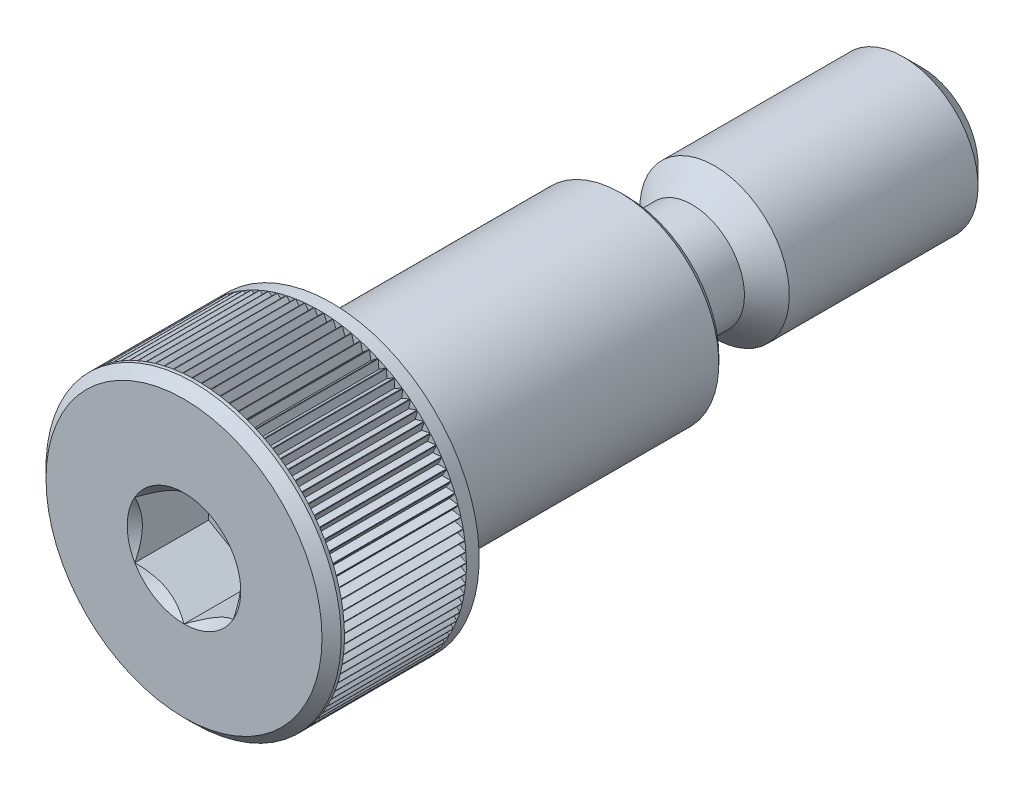
from build123d import *

# Parameters (mm, degrees)
CHAMFER1_SIZE      = 0.60325
CHAMFER2_SIZE      = 0.3095625
CHAMFER3_SIZE      = 0.2032
CUT_EXTRUDE5_DEPTH = 1.968103125
CIRPATTERN1_COUNT  = 99
CUT_EXTRUDE2_DEPTH = 2.38125


with BuildPart() as part:
    # Sketch1 → Revolve1 (revolve)
    with BuildSketch(Plane(origin=(0, 0, 0), x_dir=(0, 0, -1), z_dir=(1, 0, 0))):
        Polygon((0, 4.7625), (4.7625, 4.7625), (4.7625, 3.175), (14.2875, 3.175), (14.2875, 2.413), (23.8125, 2.413), (23.8125, 0), (0, 0), align=None)
    revolve(axis=Axis((0, 0, -23.8125), (0, 0, 1)))

    # Sketch5 → Cut-Revolve1 (revolve, cut)
    with BuildSketch(Plane(origin=(0, 0, 0), x_dir=(0, 0, -1), z_dir=(1, 0, 0))):
        with BuildLine():
            Line((14.2875, 3.175), (17.8816, 3.175))
            Line((17.8816, 3.175), (16.3957, 1.6891))
            Line((16.3957, 1.6891), (15.0114, 1.6891))
            ThreePointArc((15.0114, 1.6891), (14.499525401, 1.901125401), (14.2875, 2.413))
            Line((14.2875, 2.413), (14.2875, 3.175))
        make_face()
    revolve(axis=Axis((0, 0, -23.8125), (0, 0, 1)), mode=Mode.SUBTRACT)

    # Chamfer1
    chamfer1_edges = [part.edges().sort_by_distance(p)[0] for p in [
        (0, -2.413, -23.8125),
    ]]
    chamfer(chamfer1_edges, length=CHAMFER1_SIZE)

    # Chamfer2
    chamfer2_edges = [part.edges().sort_by_distance(p)[0] for p in [
        (0, -4.7625, 0),
    ]]
    chamfer(chamfer2_edges, length=CHAMFER2_SIZE)

    # Chamfer3
    chamfer3_edges = [part.edges().sort_by_distance(p)[0] for p in [
        (0, -3.175, -14.2875),
    ]]
    chamfer(chamfer3_edges, length=CHAMFER3_SIZE)

    # Sketch11 → Cut-Extrude5 (cut, symmetric)
    with BuildSketch(Plane.XY.offset(-2.38125)):
        Polygon((0, 4.51485), (0.142980794, 4.7625), (-0.142980794, 4.7625), align=None)
    cut_extrude5 = extrude(amount=CUT_EXTRUDE5_DEPTH, both=True, mode=Mode.SUBTRACT)

    # CirPattern1: Cut-Extrude5 ×99 about axis
    cirpattern1_axis = Axis((0, 0, -23.8125), (0, 0, -1))
    for i in range(1, CIRPATTERN1_COUNT):
        add(cut_extrude5.rotate(cirpattern1_axis, i * 360 / CIRPATTERN1_COUNT), mode=Mode.SUBTRACT)

    # Sketch8 → Cut-Extrude2 (cut)
    with BuildSketch(Plane.XY):
        Polygon((1.5875, 0.916543552), (0, 1.833087105), (-1.5875, 0.916543552), (-1.5875, -0.916543552), (0, -1.833087105), (1.5875, -0.916543552), align=None)
    extrude(amount=-CUT_EXTRUDE2_DEPTH, mode=Mode.SUBTRACT)

    # Cut-Extrude4 cone 1 section (through the dimple's axis) → Cut-Extrude4 (revolve, cut)
    with BuildSketch(Plane(origin=(0, 0, 0), x_dir=(0, -1, 0), z_dir=(1, 0, 0))):
        Polygon((0, 0), (1.833087105, 0), (0, 1.833087105), align=None)
    revolve(axis=Axis((0, 0, 0), (0, 0, -1)), mode=Mode.SUBTRACT)


solid = part.part
